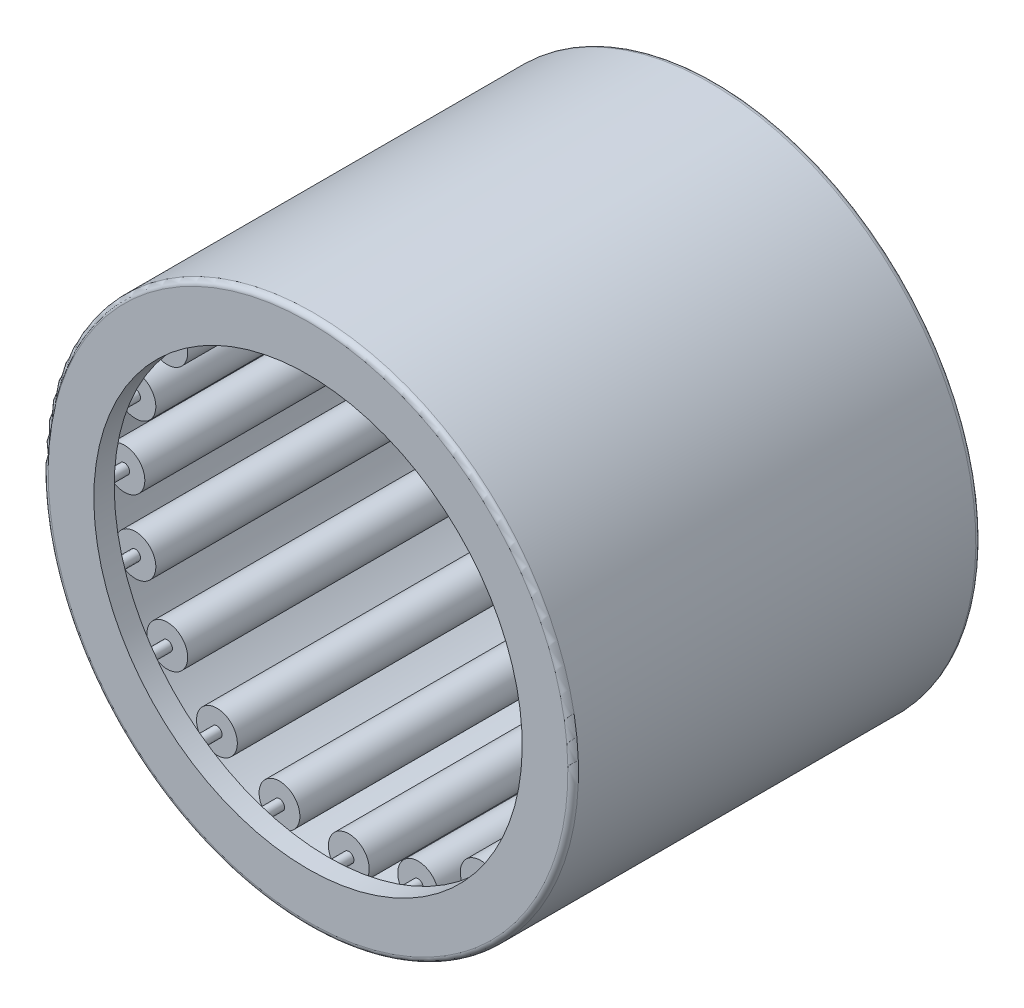
from build123d import *

# Parameters (mm, degrees)
SKETCH2_W         = 16
SKETCH2_H         = 0.75
SKETCH3_W         = 18
SKETCH3_H         = 0.25
CIRPATTERN1_COUNT = 20
CIRPATTERN1_ANGLE = 342
FILLET1_R         = 0.26


with BuildPart() as part:
    # Sketch7 → Revolve1 (revolve)
    with BuildSketch(Plane(origin=(0, 0, 0), x_dir=(0, 0, -1), z_dir=(1, 0, 0))):
        Polygon((-10, 13), (-10, 10.5), (-9, 10.5), (-9, 12), (9, 12), (9, 10.5), (10, 10.5), (10, 13), align=None)
    revolve(axis=Axis((0, 0, 10), (0, 0, -1)))

    # Fillet1
    fillet1_edges = [part.edges().sort_by_distance(p)[0] for p in [
        (0, -13, -10),
        (0, -13, 10),
    ]]
    fillet(fillet1_edges, radius=FILLET1_R)


with BuildPart() as body_2:
    # Sketch2 → Revolve2 (revolve)
    with BuildSketch(Plane(origin=(0, 0, 0), x_dir=(0, 0, -1), z_dir=(1, 0, 0))):
        with Locations((0, 11.625)):
            Rectangle(SKETCH2_W, SKETCH2_H)
    revolve(axis=Axis((0, 11, 8), (0, 0, -1)))


with BuildPart() as body_3:
    # Sketch3 → Revolve3 (revolve)
    with BuildSketch(Plane(origin=(0, 0, 0), x_dir=(0, 0, -1), z_dir=(1, 0, 0))):
        with Locations((0, 11.125)):
            Rectangle(SKETCH3_W, SKETCH3_H)
    revolve(axis=Axis((0, 11, 9), (0, 0, -1)))


with BuildPart() as cirpattern1_1:
    # CirPattern1: pattern copy
    add(body_2.part.rotate(Axis((0, 0, 10), (0, 0, -1)), 1 * CIRPATTERN1_ANGLE / (CIRPATTERN1_COUNT - 1)))


with BuildPart() as cirpattern1_2:
    # CirPattern1: pattern copy
    add(body_2.part.rotate(Axis((0, 0, 10), (0, 0, -1)), 2 * CIRPATTERN1_ANGLE / (CIRPATTERN1_COUNT - 1)))


with BuildPart() as cirpattern1_3:
    # CirPattern1: pattern copy
    add(body_2.part.rotate(Axis((0, 0, 10), (0, 0, -1)), 3 * CIRPATTERN1_ANGLE / (CIRPATTERN1_COUNT - 1)))


with BuildPart() as cirpattern1_4:
    # CirPattern1: pattern copy
    add(body_2.part.rotate(Axis((0, 0, 10), (0, 0, -1)), 4 * CIRPATTERN1_ANGLE / (CIRPATTERN1_COUNT - 1)))


with BuildPart() as cirpattern1_5:
    # CirPattern1: pattern copy
    add(body_2.part.rotate(Axis((0, 0, 10), (0, 0, -1)), 5 * CIRPATTERN1_ANGLE / (CIRPATTERN1_COUNT - 1)))


with BuildPart() as cirpattern1_6:
    # CirPattern1: pattern copy
    add(body_2.part.rotate(Axis((0, 0, 10), (0, 0, -1)), 6 * CIRPATTERN1_ANGLE / (CIRPATTERN1_COUNT - 1)))


with BuildPart() as cirpattern1_7:
    # CirPattern1: pattern copy
    add(body_2.part.rotate(Axis((0, 0, 10), (0, 0, -1)), 7 * CIRPATTERN1_ANGLE / (CIRPATTERN1_COUNT - 1)))


with BuildPart() as cirpattern1_8:
    # CirPattern1: pattern copy
    add(body_2.part.rotate(Axis((0, 0, 10), (0, 0, -1)), 8 * CIRPATTERN1_ANGLE / (CIRPATTERN1_COUNT - 1)))


with BuildPart() as cirpattern1_9:
    # CirPattern1: pattern copy
    add(body_2.part.rotate(Axis((0, 0, 10), (0, 0, -1)), 9 * CIRPATTERN1_ANGLE / (CIRPATTERN1_COUNT - 1)))


with BuildPart() as cirpattern1_10:
    # CirPattern1: pattern copy
    add(body_2.part.rotate(Axis((0, 0, 10), (0, 0, -1)), 10 * CIRPATTERN1_ANGLE / (CIRPATTERN1_COUNT - 1)))


with BuildPart() as cirpattern1_11:
    # CirPattern1: pattern copy
    add(body_2.part.rotate(Axis((0, 0, 10), (0, 0, -1)), 11 * CIRPATTERN1_ANGLE / (CIRPATTERN1_COUNT - 1)))


with BuildPart() as cirpattern1_12:
    # CirPattern1: pattern copy
    add(body_2.part.rotate(Axis((0, 0, 10), (0, 0, -1)), 12 * CIRPATTERN1_ANGLE / (CIRPATTERN1_COUNT - 1)))


with BuildPart() as cirpattern1_13:
    # CirPattern1: pattern copy
    add(body_2.part.rotate(Axis((0, 0, 10), (0, 0, -1)), 13 * CIRPATTERN1_ANGLE / (CIRPATTERN1_COUNT - 1)))


with BuildPart() as cirpattern1_14:
    # CirPattern1: pattern copy
    add(body_2.part.rotate(Axis((0, 0, 10), (0, 0, -1)), 14 * CIRPATTERN1_ANGLE / (CIRPATTERN1_COUNT - 1)))


with BuildPart() as cirpattern1_15:
    # CirPattern1: pattern copy
    add(body_2.part.rotate(Axis((0, 0, 10), (0, 0, -1)), 15 * CIRPATTERN1_ANGLE / (CIRPATTERN1_COUNT - 1)))


with BuildPart() as cirpattern1_16:
    # CirPattern1: pattern copy
    add(body_2.part.rotate(Axis((0, 0, 10), (0, 0, -1)), 16 * CIRPATTERN1_ANGLE / (CIRPATTERN1_COUNT - 1)))


with BuildPart() as cirpattern1_17:
    # CirPattern1: pattern copy
    add(body_2.part.rotate(Axis((0, 0, 10), (0, 0, -1)), 17 * CIRPATTERN1_ANGLE / (CIRPATTERN1_COUNT - 1)))


with BuildPart() as cirpattern1_18:
    # CirPattern1: pattern copy
    add(body_2.part.rotate(Axis((0, 0, 10), (0, 0, -1)), 18 * CIRPATTERN1_ANGLE / (CIRPATTERN1_COUNT - 1)))


with BuildPart() as cirpattern1_19:
    # CirPattern1: pattern copy
    add(body_2.part.rotate(Axis((0, 0, 10), (0, 0, -1)), 19 * CIRPATTERN1_ANGLE / (CIRPATTERN1_COUNT - 1)))


with BuildPart() as cirpattern1_20:
    # CirPattern1: pattern copy
    add(body_3.part.rotate(Axis((0, 0, 10), (0, 0, -1)), 1 * CIRPATTERN1_ANGLE / (CIRPATTERN1_COUNT - 1)))


with BuildPart() as cirpattern1_21:
    # CirPattern1: pattern copy
    add(body_3.part.rotate(Axis((0, 0, 10), (0, 0, -1)), 2 * CIRPATTERN1_ANGLE / (CIRPATTERN1_COUNT - 1)))


with BuildPart() as cirpattern1_22:
    # CirPattern1: pattern copy
    add(body_3.part.rotate(Axis((0, 0, 10), (0, 0, -1)), 3 * CIRPATTERN1_ANGLE / (CIRPATTERN1_COUNT - 1)))


with BuildPart() as cirpattern1_23:
    # CirPattern1: pattern copy
    add(body_3.part.rotate(Axis((0, 0, 10), (0, 0, -1)), 4 * CIRPATTERN1_ANGLE / (CIRPATTERN1_COUNT - 1)))


with BuildPart() as cirpattern1_24:
    # CirPattern1: pattern copy
    add(body_3.part.rotate(Axis((0, 0, 10), (0, 0, -1)), 5 * CIRPATTERN1_ANGLE / (CIRPATTERN1_COUNT - 1)))


with BuildPart() as cirpattern1_25:
    # CirPattern1: pattern copy
    add(body_3.part.rotate(Axis((0, 0, 10), (0, 0, -1)), 6 * CIRPATTERN1_ANGLE / (CIRPATTERN1_COUNT - 1)))


with BuildPart() as cirpattern1_26:
    # CirPattern1: pattern copy
    add(body_3.part.rotate(Axis((0, 0, 10), (0, 0, -1)), 7 * CIRPATTERN1_ANGLE / (CIRPATTERN1_COUNT - 1)))


with BuildPart() as cirpattern1_27:
    # CirPattern1: pattern copy
    add(body_3.part.rotate(Axis((0, 0, 10), (0, 0, -1)), 8 * CIRPATTERN1_ANGLE / (CIRPATTERN1_COUNT - 1)))


with BuildPart() as cirpattern1_28:
    # CirPattern1: pattern copy
    add(body_3.part.rotate(Axis((0, 0, 10), (0, 0, -1)), 9 * CIRPATTERN1_ANGLE / (CIRPATTERN1_COUNT - 1)))


with BuildPart() as cirpattern1_29:
    # CirPattern1: pattern copy
    add(body_3.part.rotate(Axis((0, 0, 10), (0, 0, -1)), 10 * CIRPATTERN1_ANGLE / (CIRPATTERN1_COUNT - 1)))


with BuildPart() as cirpattern1_30:
    # CirPattern1: pattern copy
    add(body_3.part.rotate(Axis((0, 0, 10), (0, 0, -1)), 11 * CIRPATTERN1_ANGLE / (CIRPATTERN1_COUNT - 1)))


with BuildPart() as cirpattern1_31:
    # CirPattern1: pattern copy
    add(body_3.part.rotate(Axis((0, 0, 10), (0, 0, -1)), 12 * CIRPATTERN1_ANGLE / (CIRPATTERN1_COUNT - 1)))


with BuildPart() as cirpattern1_32:
    # CirPattern1: pattern copy
    add(body_3.part.rotate(Axis((0, 0, 10), (0, 0, -1)), 13 * CIRPATTERN1_ANGLE / (CIRPATTERN1_COUNT - 1)))


with BuildPart() as cirpattern1_33:
    # CirPattern1: pattern copy
    add(body_3.part.rotate(Axis((0, 0, 10), (0, 0, -1)), 14 * CIRPATTERN1_ANGLE / (CIRPATTERN1_COUNT - 1)))


with BuildPart() as cirpattern1_34:
    # CirPattern1: pattern copy
    add(body_3.part.rotate(Axis((0, 0, 10), (0, 0, -1)), 15 * CIRPATTERN1_ANGLE / (CIRPATTERN1_COUNT - 1)))


with BuildPart() as cirpattern1_35:
    # CirPattern1: pattern copy
    add(body_3.part.rotate(Axis((0, 0, 10), (0, 0, -1)), 16 * CIRPATTERN1_ANGLE / (CIRPATTERN1_COUNT - 1)))


with BuildPart() as cirpattern1_36:
    # CirPattern1: pattern copy
    add(body_3.part.rotate(Axis((0, 0, 10), (0, 0, -1)), 17 * CIRPATTERN1_ANGLE / (CIRPATTERN1_COUNT - 1)))


with BuildPart() as cirpattern1_37:
    # CirPattern1: pattern copy
    add(body_3.part.rotate(Axis((0, 0, 10), (0, 0, -1)), 18 * CIRPATTERN1_ANGLE / (CIRPATTERN1_COUNT - 1)))


with BuildPart() as cirpattern1_38:
    # CirPattern1: pattern copy
    add(body_3.part.rotate(Axis((0, 0, 10), (0, 0, -1)), 19 * CIRPATTERN1_ANGLE / (CIRPATTERN1_COUNT - 1)))


solid = Compound([part.part, body_2.part, body_3.part, cirpattern1_1.part, cirpattern1_2.part, cirpattern1_3.part, cirpattern1_4.part, cirpattern1_5.part, cirpattern1_6.part, cirpattern1_7.part, cirpattern1_8.part, cirpattern1_9.part, cirpattern1_10.part, cirpattern1_11.part, cirpattern1_12.part, cirpattern1_13.part, cirpattern1_14.part, cirpattern1_15.part, cirpattern1_16.part, cirpattern1_17.part, cirpattern1_18.part, cirpattern1_19.part, cirpattern1_20.part, cirpattern1_21.part, cirpattern1_22.part, cirpattern1_23.part, cirpattern1_24.part, cirpattern1_25.part, cirpattern1_26.part, cirpattern1_27.part, cirpattern1_28.part, cirpattern1_29.part, cirpattern1_30.part, cirpattern1_31.part, cirpattern1_32.part, cirpattern1_33.part, cirpattern1_34.part, cirpattern1_35.part, cirpattern1_36.part, cirpattern1_37.part, cirpattern1_38.part])
